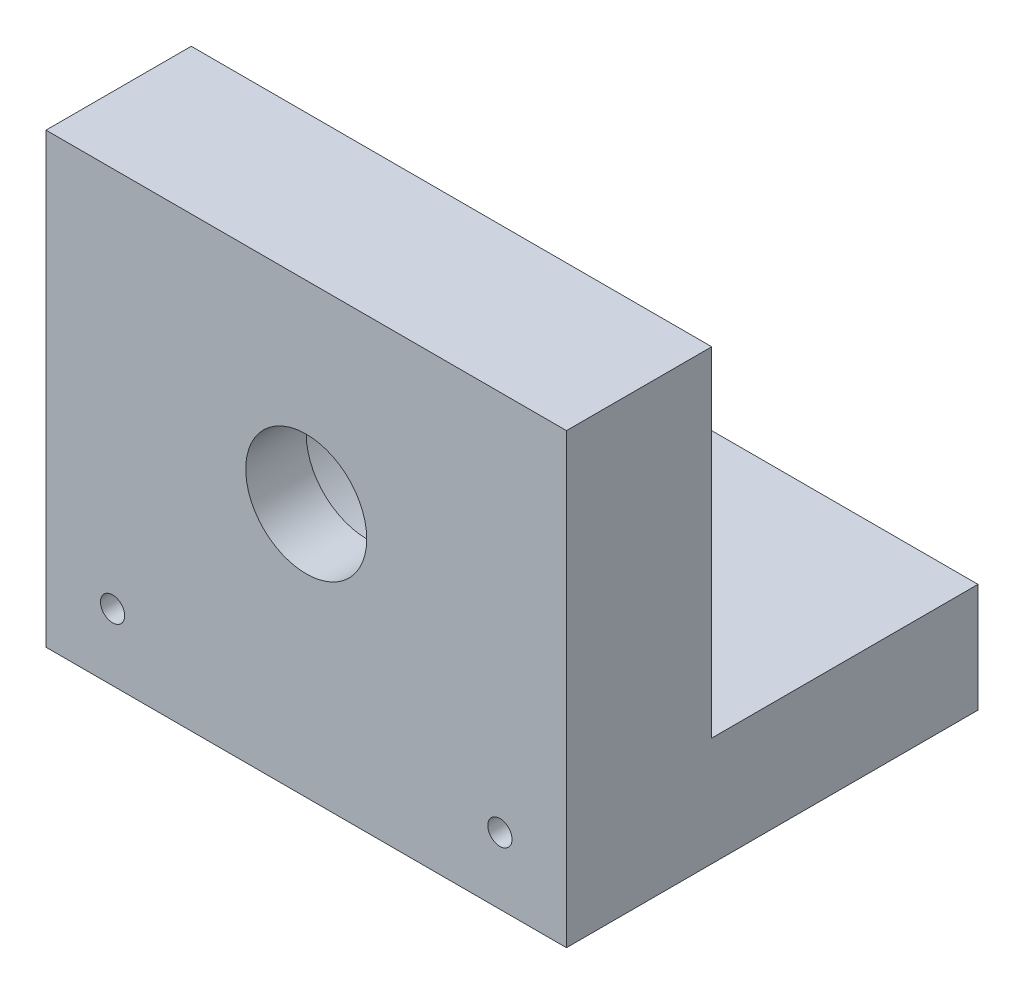
from build123d import *

# Parameters (mm, degrees)
SKETCH2_W           = 43
SKETCH2_H           = 37
SKETCH2_R           = 5
BOSS_EXTRUDE1_DEPTH = 12
SKETCH3_R           = 11
CUT_EXTRUDE1_DEPTH  = 7
SKETCH4_W           = 43
SKETCH4_H           = 34
BOSS_EXTRUDE2_DEPTH = 9
SKETCH5_R           = 1
CUT_EXTRUDE2_DEPTH  = 10


with BuildPart() as part:
    # Sketch2 → Boss-Extrude1 (new body)
    with BuildSketch(Plane.XY):
        with Locations((21.5, 18.5)):
            Rectangle(SKETCH2_W, SKETCH2_H)
        with Locations((21.5, 21)):
            Circle(SKETCH2_R, mode=Mode.SUBTRACT)
    extrude(amount=-BOSS_EXTRUDE1_DEPTH)

    # Sketch3 → Cut-Extrude1 (cut)
    with BuildSketch(Plane(origin=(0, 0, -12), x_dir=(-1, 0, 0), z_dir=(0, 0, -1))):
        with Locations((-21.5, 21)):
            Circle(SKETCH3_R)
    extrude(amount=-CUT_EXTRUDE1_DEPTH, mode=Mode.SUBTRACT)

    # Sketch4 → Boss-Extrude2 (add)
    with BuildSketch(Plane.XZ):
        with Locations((21.5, -17)):
            Rectangle(SKETCH4_W, SKETCH4_H)
    extrude(amount=-BOSS_EXTRUDE2_DEPTH)

    # Sketch5 → Cut-Extrude2 (cut)
    with BuildSketch(Plane.XY):
        with Locations((5.5, 5.5)):
            Circle(SKETCH5_R)
        with Locations((37.5, 5.5)):
            Circle(SKETCH5_R)
    extrude(amount=-CUT_EXTRUDE2_DEPTH, mode=Mode.SUBTRACT)


solid = part.part
